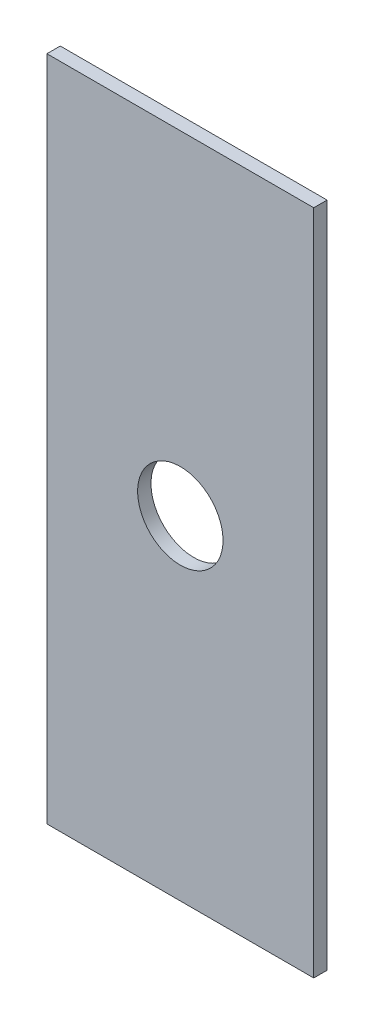
from build123d import *

# Parameters (mm, degrees)
SKETCH1_W           = 60
SKETCH1_H           = 150
SKETCH1_R           = 9.6
BOSS_EXTRUDE1_DEPTH = 3


with BuildPart() as part:
    # Sketch1 → Boss-Extrude1 (new body)
    with BuildSketch(Plane.XY):
        with Locations((-29.165217391, -62.360869565)):
            Rectangle(SKETCH1_W, SKETCH1_H)
        with Locations((-29.165217391, -62.360869565)):
            Circle(SKETCH1_R, mode=Mode.SUBTRACT)
    extrude(amount=BOSS_EXTRUDE1_DEPTH)


solid = part.part
